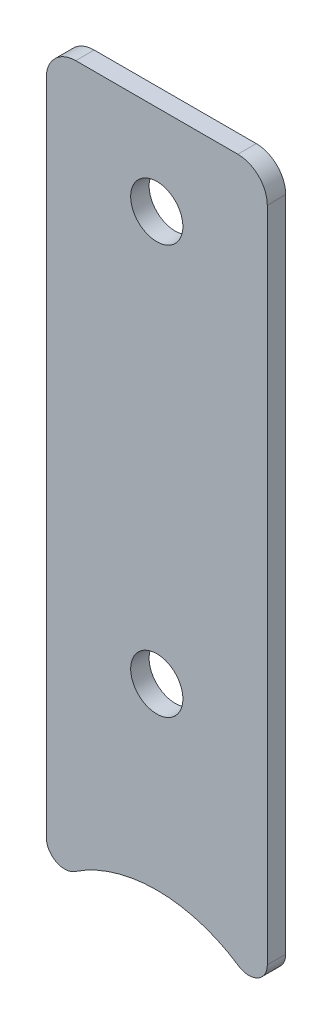
from build123d import *

# Parameters (mm, degrees)
SKETCH1_W            = 19.05
SKETCH1_H            = 50.8
BOSS_EXTRUDE1_DEPTH  = 1.5875
M4_CLEARANCE_HOLE1_D = 4.5
SKETCH4_W            = 19.05
SKETCH4_H            = 7.62
BOSS_EXTRUDE2_DEPTH  = 1.5875
FILLET1_R            = 2.54
BOSS_EXTRUDE3_DEPTH  = 1.5875
FILLET2_R            = 1.5875


with BuildPart() as part:
    # Sketch1 → Boss-Extrude1 (new body)
    with BuildSketch(Plane.XY):
        Rectangle(SKETCH1_W, SKETCH1_H)
    extrude(amount=BOSS_EXTRUDE1_DEPTH)

    # M4 Clearance Hole1 (through all)
    with Locations(Plane.XY.offset(1.5875)):
        with Locations((0, 17.6276), (0, -17.6276)):
            Hole(M4_CLEARANCE_HOLE1_D / 2)

    # Sketch4 → Boss-Extrude2 (add)
    with BuildSketch(Plane.XY.offset(1.5875)):
        with Locations((0, -29.21)):
            Rectangle(SKETCH4_W, SKETCH4_H)
    extrude(amount=-BOSS_EXTRUDE2_DEPTH)

    # Fillet1
    fillet1_edges = [part.edges().sort_by_distance(p)[0] for p in [
        (-9.525, 25.4, 0.79375),
        (9.525, 25.4, 0.79375),
    ]]
    fillet(fillet1_edges, radius=FILLET1_R)

    # Sketch5 → Boss-Extrude3 (add)
    with BuildSketch(Plane.XY.offset(1.5875)):
        with BuildLine():
            Line((1.5e-08, -33.02), (-9.525, -33.02))
            Line((-9.525, -33.02), (-9.525, -37.319739587))
            ThreePointArc((-9.525, -37.319739587), (-5.225260406, -34.144739584), (1.5e-08, -33.02))
        make_face()
        with BuildLine():
            Line((9.525, -33.02), (1.5e-08, -33.02))
            ThreePointArc((1.5e-08, -33.02), (5.225260419, -34.14473959), (9.525, -37.319739587))
            Line((9.525, -37.319739587), (9.525, -33.02))
        make_face()
    extrude(amount=-BOSS_EXTRUDE3_DEPTH)

    # Fillet2
    fillet2_edges = [part.edges().sort_by_distance(p)[0] for p in [
        (-9.525, -37.319739587, 0.79375),
        (9.525, -37.319739587, 0.79375),
    ]]
    fillet(fillet2_edges, radius=FILLET2_R)


solid = part.part
